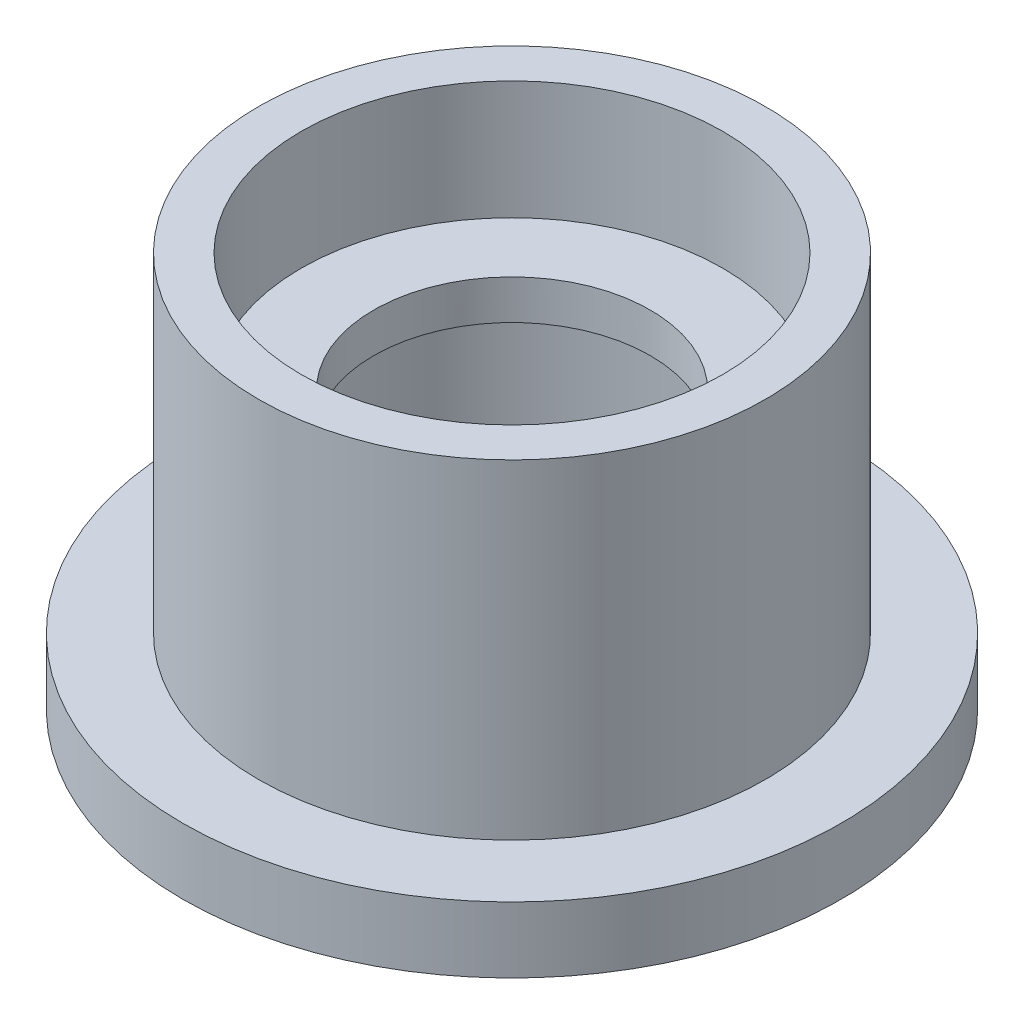
from build123d import *

# Parameters (mm, degrees)
SKETCH1_R           = 25
BOSS_EXTRUDE1_DEPTH = 30
SKETCH2_OUTSIDE_W   = 67.362
SKETCH2_OUTSIDE_H   = 67.362
SKETCH2_OUTSIDE_R   = 19.25
CUT_EXTRUDE1_DEPTH  = 25
SKETCH3_R           = 16
CUT_EXTRUDE2_DEPTH  = 9
SKETCH4_R           = 10.5
CUT_EXTRUDE3_DEPTH  = 22
SKETCH5_R           = 16
CUT_EXTRUDE4_DEPTH  = 18


with BuildPart() as part:
    # Sketch1 → Boss-Extrude1 (new body)
    with BuildSketch(Plane(origin=(0, 0, 0), x_dir=(1, 0, 0), z_dir=(0, 1, 0))):
        Circle(SKETCH1_R)
    extrude(amount=BOSS_EXTRUDE1_DEPTH)

    # Sketch2 outside → Cut-Extrude1 (cut)
    with BuildSketch(Plane(origin=(0, 30, 0), x_dir=(1, 0, 0), z_dir=(0, 1, 0))):
        Rectangle(SKETCH2_OUTSIDE_W, SKETCH2_OUTSIDE_H)
        Circle(SKETCH2_OUTSIDE_R, mode=Mode.SUBTRACT)
    extrude(amount=-CUT_EXTRUDE1_DEPTH, mode=Mode.SUBTRACT)

    # Sketch3 → Cut-Extrude2 (cut)
    with BuildSketch(Plane(origin=(0, 30, 0), x_dir=(1, 0, 0), z_dir=(0, 1, 0))):
        Circle(SKETCH3_R)
    extrude(amount=-CUT_EXTRUDE2_DEPTH, mode=Mode.SUBTRACT)

    # Sketch4 → Cut-Extrude3 (cut, through all)
    with BuildSketch(Plane(origin=(0, 21, 0), x_dir=(1, 0, 0), z_dir=(0, 1, 0))):
        Circle(SKETCH4_R)
    extrude(amount=-CUT_EXTRUDE3_DEPTH, mode=Mode.SUBTRACT)

    # Sketch5 → Cut-Extrude4 (cut)
    with BuildSketch(Plane.XZ):
        Circle(SKETCH5_R)
    extrude(amount=-CUT_EXTRUDE4_DEPTH, mode=Mode.SUBTRACT)


solid = part.part
